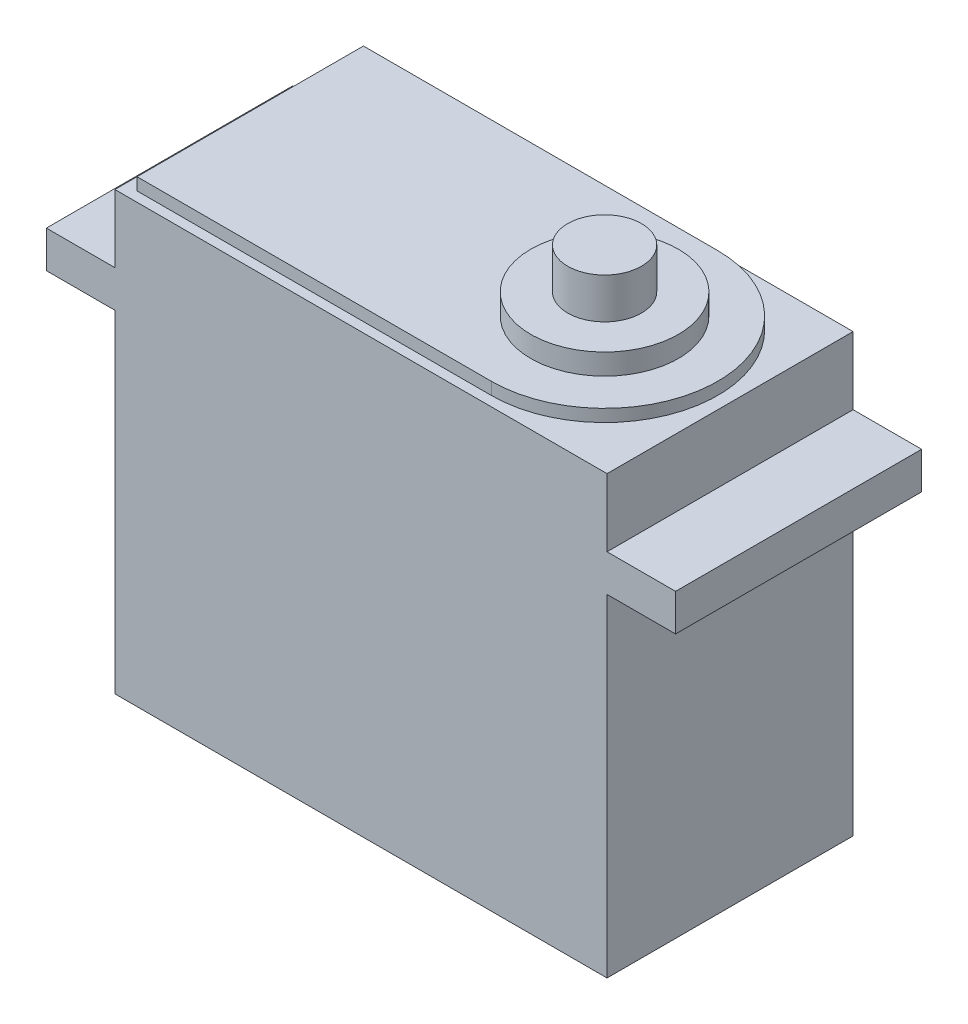
from build123d import *

# Parameters (mm, degrees)
RESSALTO_EXTRUS_O1_DEPTH = 10
RESSALTO_EXTRUS_O2_DEPTH = 1
ESBO_O4_R                = 3
RESSALTO_EXTRUS_O3_DEPTH = 5
ESBO_O5_R                = 6
RESSALTO_EXTRUS_O4_DEPTH = 1.7


with BuildPart() as part:
    # Esboço1 → Ressalto-extrusão1 (new body, symmetric)
    with BuildSketch(Plane.XY):
        Polygon((20, -0.767915455), (25.568877633, -0.767915455), (25.568877633, -3.767915455), (20, -3.767915455), (20, -30.767915455), (-20, -30.767915455), (-20, -3.767915455), (-25.568877633, -3.767915455), (-25.568877633, -0.767915455), (-20, -0.767915455), (-20, 4.732084545), (20, 4.732084545), align=None)
    extrude(amount=RESSALTO_EXTRUS_O1_DEPTH, both=True)

    # Esboço3 → Ressalto-extrusão2 (add)
    with BuildSketch(Plane(origin=(0, 4.732084545, 0), x_dir=(1, 0, 0), z_dir=(0, 1, 0))):
        with BuildLine():
            Line((-19, 9.2), (9.8, 9.2))
            ThreePointArc((9.8, 9.2), (19, 0), (9.8, -9.2))
            Line((9.8, -9.2), (-19, -9.2))
            Line((-19, -9.2), (-19, 9.2))
        make_face()
    extrude(amount=RESSALTO_EXTRUS_O2_DEPTH)

    # Esboço4 → Ressalto-extrusão3 (add)
    with BuildSketch(Plane(origin=(0, 5.732084545, 0), x_dir=(1, 0, 0), z_dir=(0, 1, 0))):
        with Locations((9.8, 0)):
            Circle(ESBO_O4_R)
    extrude(amount=RESSALTO_EXTRUS_O3_DEPTH)

    # Esboço5 → Ressalto-extrusão4 (add)
    with BuildSketch(Plane(origin=(0, 5.732084545, 0), x_dir=(1, 0, 0), z_dir=(0, 1, 0))):
        with Locations((9.8, 0)):
            Circle(ESBO_O5_R)
    extrude(amount=RESSALTO_EXTRUS_O4_DEPTH)


solid = part.part
